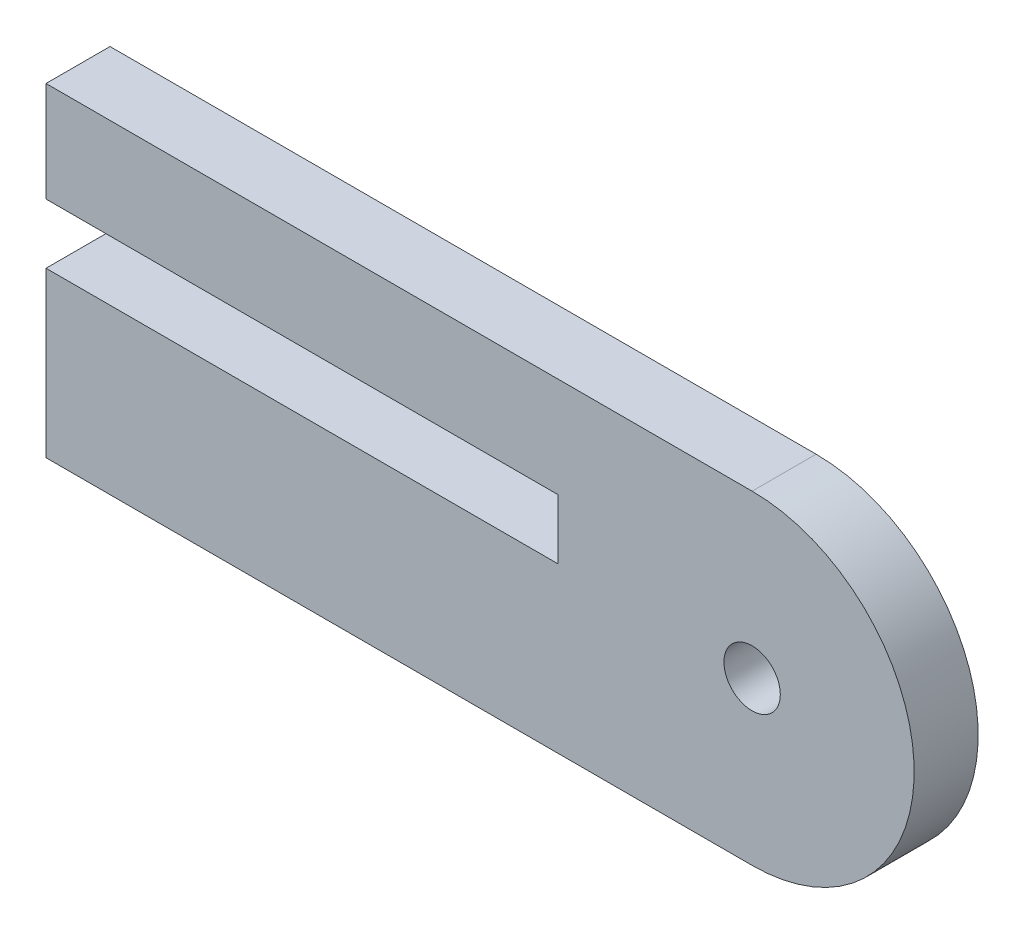
from build123d import *

# Parameters (mm, degrees)
SKETCH1_R           = 1.3984
BOSS_EXTRUDE1_DEPTH = 3.175


with BuildPart() as part:
    # Sketch1 → Boss-Extrude1 (new body)
    with BuildSketch(Plane.XY):
        with BuildLine():
            Line((-0.1016, 15.9766), (34.925, 15.9766))
            ThreePointArc((34.925, 15.9766), (42.9641, 7.9375), (34.925, -0.1016))
            Line((34.925, -0.1016), (-0.1016, -0.1016))
            Line((-0.1016, -0.1016), (-0.1016, 4.7625))
            Line((-0.1016, 4.7625), (-0.1016, 8.0391))
            Line((-0.1016, 8.0391), (25.2984, 8.0391))
            Line((25.2984, 8.0391), (25.2984, 11.0109))
            Line((25.2984, 11.0109), (-0.1016, 11.0109))
            Line((-0.1016, 11.0109), (-0.1016, 15.9766))
        make_face()
        with Locations((34.925, 7.9375)):
            Circle(SKETCH1_R, mode=Mode.SUBTRACT)
    extrude(amount=BOSS_EXTRUDE1_DEPTH)


solid = part.part
